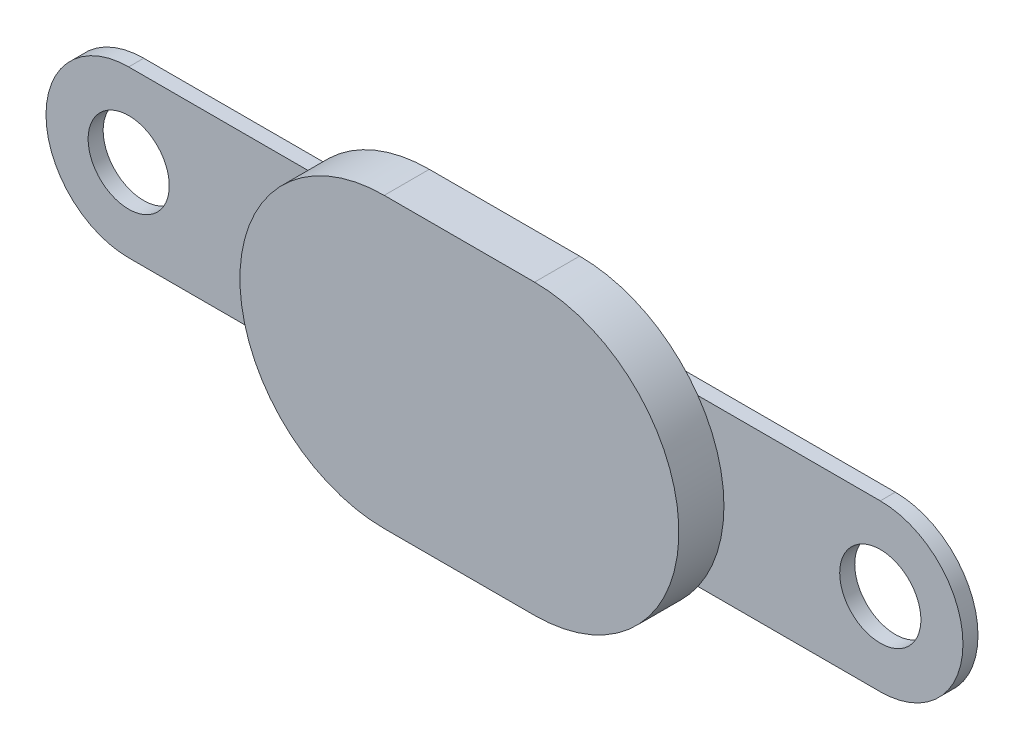
from build123d import *

# Parameters (mm, degrees)
BOSS_EXTRUDE2_DEPTH = 1.5
SKETCH4_R           = 1.35
BOSS_EXTRUDE4_DEPTH = 0.5


with BuildPart() as part:
    # Sketch2 → Boss-Extrude2 (new body)
    with BuildSketch(Plane.XY):
        with BuildLine():
            Line((-2.5, -4.8), (2.5, -4.8))
            ThreePointArc((2.5, -4.8), (7.3, 0), (2.5, 4.8))
            Line((2.5, 4.8), (-2.5, 4.8))
            ThreePointArc((-2.5, 4.8), (-7.3, 0), (-2.5, -4.8))
        make_face()
    extrude(amount=BOSS_EXTRUDE2_DEPTH)

    # Sketch4 → Boss-Extrude4 (add)
    with BuildSketch(Plane(origin=(0, 0, 0), x_dir=(-1, 0, 0), z_dir=(0, 0, -1))):
        with BuildLine():
            Line((-12.5, -2.75), (12.5, -2.75))
            ThreePointArc((12.5, -2.75), (15.25, 0), (12.5, 2.75))
            Line((12.5, 2.75), (-12.5, 2.75))
            ThreePointArc((-12.5, 2.75), (-15.25, 0), (-12.5, -2.75))
        make_face()
        with Locations((-12.5, 0)):
            Circle(SKETCH4_R, mode=Mode.SUBTRACT)
        with Locations((12.5, 0)):
            Circle(SKETCH4_R, mode=Mode.SUBTRACT)
    extrude(amount=BOSS_EXTRUDE4_DEPTH)


solid = part.part
